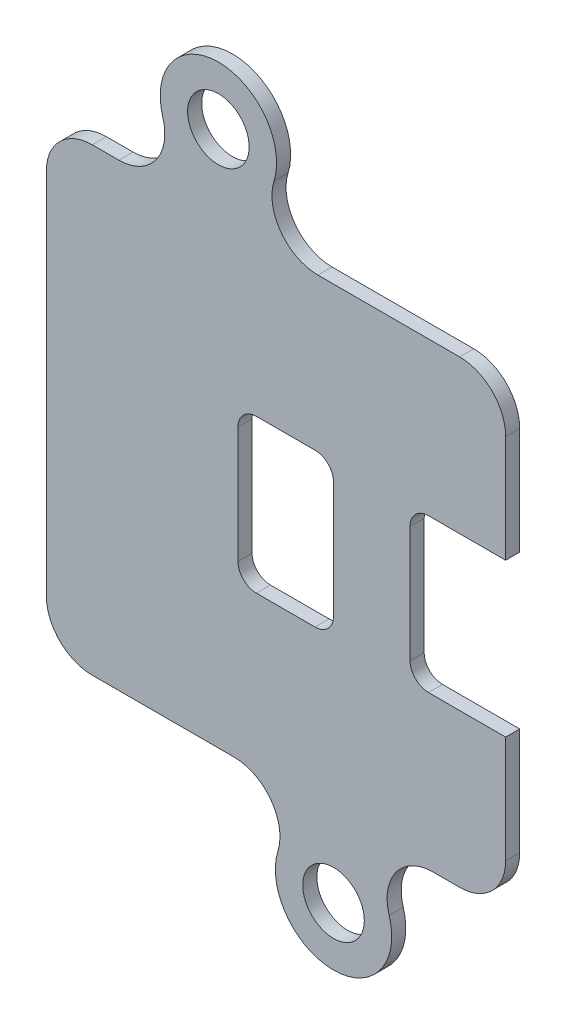
from build123d import *

# Parameters (mm, degrees)
SKETCH1_R           = 2.5527
SKETCH1_W           = 7.9248
SKETCH1_H           = 12.7
BOSS_EXTRUDE1_DEPTH = 0.5842
FILLET1_R           = 3.81
FILLET2_R           = 1.524


with BuildPart() as part:
    # Sketch1 → Boss-Extrude1 (new body, symmetric)
    with BuildSketch(Plane.XY):
        with BuildLine():
            ThreePointArc((-4.612542275, 1.419411765), (0, -4.826), (4.612542275, 1.419411765))
            ThreePointArc((4.612542275, 1.419411765), (5.18926029, 4.803477283), (8.254023019, 6.35))
            Line((8.254023019, 6.35), (14.2748, 6.35))
            Line((14.2748, 6.35), (14.2748, 19.05))
            Line((14.2748, 19.05), (6.35, 19.05))
            Line((6.35, 19.05), (6.35, 31.75))
            Line((6.35, 31.75), (14.2748, 31.75))
            Line((14.2748, 31.75), (14.2748, 44.45))
            Line((14.2748, 44.45), (-1.296376981, 44.45))
            ThreePointArc((-1.296376981, 44.45), (-4.36113971, 45.996522717), (-4.937857725, 49.380588235))
            ThreePointArc((-4.937857725, 49.380588235), (-9.5504, 55.626), (-14.162942275, 49.380588235))
            ThreePointArc((-14.162942275, 49.380588235), (-14.73966029, 45.996522717), (-17.804423019, 44.45))
            Line((-17.804423019, 44.45), (-23.8252, 44.45))
            Line((-23.8252, 44.45), (-23.8252, 6.35))
            Line((-23.8252, 6.35), (-8.254023019, 6.35))
            ThreePointArc((-8.254023019, 6.35), (-5.18926029, 4.803477283), (-4.612542275, 1.419411765))
        make_face()
        Circle(SKETCH1_R, mode=Mode.SUBTRACT)
        with Locations((-9.5504, 50.8)):
            Circle(SKETCH1_R, mode=Mode.SUBTRACT)
        with Locations((-3.9624, 25.4)):
            Rectangle(SKETCH1_W, SKETCH1_H, mode=Mode.SUBTRACT)
    extrude(amount=BOSS_EXTRUDE1_DEPTH, both=True)

    # Fillet1
    fillet1_edges = [part.edges().sort_by_distance(p)[0] for p in [
        (-23.8252, 6.35, 0),
        (-23.8252, 44.45, 0),
        (14.2748, 44.45, 0),
        (14.2748, 6.35, 0),
    ]]
    fillet(fillet1_edges, radius=FILLET1_R)

    # Fillet2
    fillet2_edges = [part.edges().sort_by_distance(p)[0] for p in [
        (6.35, 31.75, 0),
        (6.35, 19.05, 0),
        (-7.9248, 19.05, 0),
        (0, 19.05, 0),
        (0, 31.75, 0),
        (-7.9248, 31.75, 0),
    ]]
    fillet(fillet2_edges, radius=FILLET2_R)


solid = part.part
